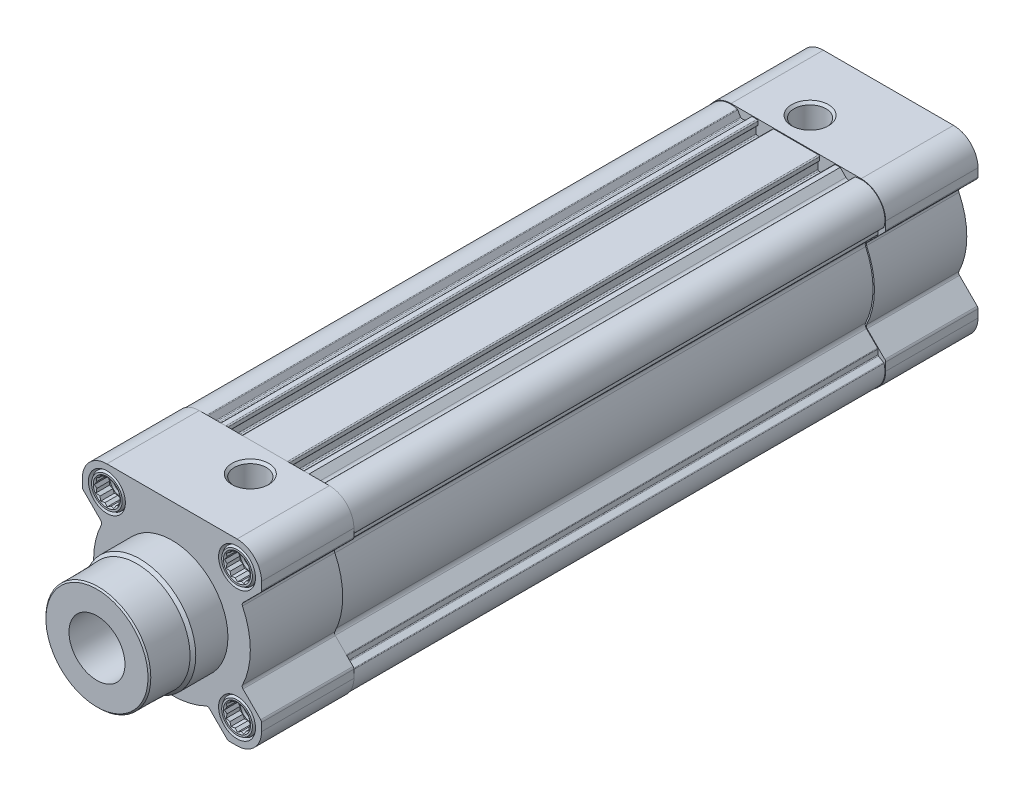
from build123d import *

# Parameters (mm, degrees)
BOSS_EXTRUDE1_DEPTH  = 33
BOSS_EXTRUDE2_DEPTH  = 190
SKETCH3_W            = 76.8
SKETCH3_H            = 76.8
CUT_EXTRUDE1_DEPTH   = 190
BOSS_EXTRUDE3_DEPTH  = 33
HOLE1_D              = 11.445
HOLE1_DEPTH          = 32
HOLE1_CSINK_D        = 13.157
HOLE1_CSINK_ANGLE    = 90
SKETCH8_W            = 24.5
SKETCH8_H            = 6.6
LPATTERN1_COUNT      = 2
LPATTERN1_PITCH      = 46.5
LPATTERN1_COUNT_DIR2 = 2
LPATTERN1_PITCH_DIR2 = 46.5
LPATTERN2_COUNT      = 2
LPATTERN2_PITCH      = 46.5
LPATTERN2_COUNT_DIR2 = 2
LPATTERN2_PITCH_DIR2 = 46.5
CUT_EXTRUDE2_DEPTH   = 5
LPATTERN3_COUNT      = 2
LPATTERN3_PITCH      = 46.5
LPATTERN3_COUNT_DIR2 = 2
LPATTERN3_PITCH_DIR2 = 46.5
LPATTERN4_COUNT      = 2
LPATTERN4_PITCH      = 46.5
LPATTERN4_COUNT_DIR2 = 2
LPATTERN4_PITCH_DIR2 = 46.5
HOLE2_D              = 11.445
HOLE2_DEPTH          = 32
HOLE2_CSINK_D        = 13.157
HOLE2_CSINK_ANGLE    = 90
HOLE3_D              = 13.2
HOLE3_DEPTH          = 24.5
LPATTERN5_COUNT      = 2
LPATTERN5_PITCH      = 46.5
LPATTERN5_COUNT_DIR2 = 2
LPATTERN5_PITCH_DIR2 = 46.5
LPATTERN6_COUNT      = 2
LPATTERN6_PITCH      = 46.5
LPATTERN6_COUNT_DIR2 = 2
LPATTERN6_PITCH_DIR2 = 46.5
LPATTERN7_COUNT      = 2
LPATTERN7_PITCH      = 46.5
LPATTERN7_COUNT_DIR2 = 2
LPATTERN7_PITCH_DIR2 = 46.5
CUT_EXTRUDE3_DEPTH   = 5
LPATTERN8_COUNT      = 2
LPATTERN8_PITCH      = 46.5
LPATTERN8_COUNT_DIR2 = 2
LPATTERN8_PITCH_DIR2 = 46.5


with BuildPart() as part:
    # Sketch1 → Boss-Extrude1 (new body)
    with BuildSketch(Plane.XY.offset(-33)):
        with BuildLine():
            Line((-31.707106781, 19.686291501), (-25.38500441, 13.36418913))
            ThreePointArc((-25.38500441, 13.36418913), (-25.10600235, 12.82318278), (-25.192383219, 12.220631233))
            ThreePointArc((-25.192383219, 12.220631233), (-28, 0), (-25.192383219, -12.220631233))
            ThreePointArc((-25.192383219, -12.220631233), (-25.10600235, -12.82318278), (-25.38500441, -13.36418913))
            Line((-25.38500441, -13.36418913), (-31.707106781, -19.686291501))
            ThreePointArc((-31.707106781, -19.686291501), (-31.923879533, -20.01071485), (-32, -20.393398282))
            Line((-32, -20.393398282), (-32, -23.25))
            ThreePointArc((-32, -23.25), (-29.437184335, -29.437184335), (-23.25, -32))
            Line((-23.25, -32), (-20.393398282, -32))
            ThreePointArc((-20.393398282, -32), (-20.01071485, -31.923879533), (-19.686291501, -31.707106781))
            Line((-19.686291501, -31.707106781), (-13.36418913, -25.38500441))
            ThreePointArc((-13.36418913, -25.38500441), (-12.82318278, -25.10600235), (-12.220631233, -25.192383219))
            ThreePointArc((-12.220631233, -25.192383219), (0, -28), (12.220631233, -25.192383219))
            ThreePointArc((12.220631233, -25.192383219), (12.82318278, -25.10600235), (13.36418913, -25.38500441))
            Line((13.36418913, -25.38500441), (19.686291501, -31.707106781))
            ThreePointArc((19.686291501, -31.707106781), (20.01071485, -31.923879533), (20.393398282, -32))
            Line((20.393398282, -32), (23.25, -32))
            ThreePointArc((23.25, -32), (29.437184335, -29.437184335), (32, -23.25))
            Line((32, -23.25), (32, -20.393398282))
            ThreePointArc((32, -20.393398282), (31.923879533, -20.01071485), (31.707106781, -19.686291501))
            Line((31.707106781, -19.686291501), (25.38500441, -13.36418913))
            ThreePointArc((25.38500441, -13.36418913), (25.10600235, -12.82318278), (25.192383219, -12.220631233))
            ThreePointArc((25.192383219, -12.220631233), (28, 0), (25.192383219, 12.220631233))
            ThreePointArc((25.192383219, 12.220631233), (25.10600235, 12.82318278), (25.38500441, 13.36418913))
            Line((25.38500441, 13.36418913), (31.707106781, 19.686291501))
            ThreePointArc((31.707106781, 19.686291501), (31.923879533, 20.01071485), (32, 20.393398282))
            Line((32, 20.393398282), (32, 23.25))
            ThreePointArc((32, 23.25), (29.437184335, 29.437184335), (23.25, 32))
            Line((23.25, 32), (-23.25, 32))
            ThreePointArc((-23.25, 32), (-29.437184335, 29.437184335), (-32, 23.25))
            Line((-32, 23.25), (-32, 20.393398282))
            ThreePointArc((-32, 20.393398282), (-31.923879533, 20.01071485), (-31.707106781, 19.686291501))
        make_face()
    extrude(amount=BOSS_EXTRUDE1_DEPTH)

    # Sketch2 → Boss-Extrude2 (add)
    with BuildSketch(Plane.XY.offset(-33)):
        with BuildLine():
            Line((-31.75, 20.08273811), (-25.296126931, 13.628865041))
            ThreePointArc((-25.296126931, 13.628865041), (-24.87846612, 12.822305384), (-25.00284256, 11.922577907))
            ThreePointArc((-25.00284256, 11.922577907), (-27.7, 0), (-25.00284256, -11.922577907))
            ThreePointArc((-25.00284256, -11.922577907), (-24.87846612, -12.822305384), (-25.296126931, -13.628865041))
            Line((-25.296126931, -13.628865041), (-31.75, -20.08273811))
            Line((-31.75, -20.08273811), (-31.75, -23.5))
            ThreePointArc((-31.75, -23.5), (-29.333630945, -29.333630945), (-23.5, -31.75))
            Line((-23.5, -31.75), (-20.08273811, -31.75))
            Line((-20.08273811, -31.75), (-13.628865041, -25.296126931))
            ThreePointArc((-13.628865041, -25.296126931), (-12.822305384, -24.87846612), (-11.922577907, -25.00284256))
            ThreePointArc((-11.922577907, -25.00284256), (0, -27.7), (11.922577907, -25.00284256))
            ThreePointArc((11.922577907, -25.00284256), (12.822305384, -24.87846612), (13.628865041, -25.296126931))
            Line((13.628865041, -25.296126931), (20.08273811, -31.75))
            Line((20.08273811, -31.75), (23.5, -31.75))
            ThreePointArc((23.5, -31.75), (29.333630945, -29.333630945), (31.75, -23.5))
            Line((31.75, -23.5), (31.75, -20.08273811))
            Line((31.75, -20.08273811), (25.296126931, -13.628865041))
            ThreePointArc((25.296126931, -13.628865041), (24.87846612, -12.822305384), (25.00284256, -11.922577907))
            ThreePointArc((25.00284256, -11.922577907), (27.7, 0), (25.00284256, 11.922577907))
            ThreePointArc((25.00284256, 11.922577907), (24.87846612, 12.822305384), (25.296126931, 13.628865041))
            Line((25.296126931, 13.628865041), (31.75, 20.08273811))
            Line((31.75, 20.08273811), (31.75, 23.5))
            ThreePointArc((31.75, 23.5), (29.333630945, 29.333630945), (23.5, 31.75))
            Line((23.5, 31.75), (-23.5, 31.75))
            ThreePointArc((-23.5, 31.75), (-29.333630945, 29.333630945), (-31.75, 23.5))
            Line((-31.75, 23.5), (-31.75, 20.08273811))
        make_face()
    extrude(amount=-BOSS_EXTRUDE2_DEPTH)

    # Sketch3 → Cut-Extrude1 (cut)
    with BuildSketch(Plane.XY.offset(-33)):
        Rectangle(SKETCH3_W, SKETCH3_H)
        with BuildLine():
            Line((-20.847700821, -31.237836974), (-19.815492663, -29.45))
            ThreePointArc((-19.815492663, -29.45), (-19.669082502, -29.303589838), (-19.469082502, -29.25))
            Line((-19.469082502, -29.25), (-17.748423535, -29.25))
            ThreePointArc((-17.748423535, -29.25), (-17.595350162, -29.219551813), (-17.465580823, -29.132842712))
            Line((-17.465580823, -29.132842712), (-13.478767922, -25.146029812))
            ThreePointArc((-13.478767922, -25.146029812), (-12.674014627, -24.728680623), (-11.775791832, -24.851171536))
            ThreePointArc((-11.775791832, -24.851171536), (0, -27.5), (11.775791832, -24.851171536))
            ThreePointArc((11.775791832, -24.851171536), (12.674014627, -24.728680623), (13.478767922, -25.146029812))
            Line((13.478767922, -25.146029812), (17.465580823, -29.132842712))
            ThreePointArc((17.465580823, -29.132842712), (17.595350162, -29.219551813), (17.748423535, -29.25))
            Line((17.748423535, -29.25), (19.469082502, -29.25))
            ThreePointArc((19.469082502, -29.25), (19.669082502, -29.303589838), (19.815492663, -29.45))
            Line((19.815492663, -29.45), (20.847700821, -31.237836974))
            ThreePointArc((20.847700821, -31.237836974), (20.947545902, -31.352806276), (21.083122856, -31.422130658))
            ThreePointArc((21.083122856, -31.422130658), (29.304341623, -29.304341623), (31.422130658, -21.083122856))
            ThreePointArc((31.422130658, -21.083122856), (31.352806276, -20.947545902), (31.237836974, -20.847700821))
            Line((31.237836974, -20.847700821), (29.45, -19.815492663))
            ThreePointArc((29.45, -19.815492663), (29.303589838, -19.669082502), (29.25, -19.469082502))
            Line((29.25, -19.469082502), (29.25, -17.748423535))
            ThreePointArc((29.25, -17.748423535), (29.219551813, -17.595350162), (29.132842712, -17.465580823))
            Line((29.132842712, -17.465580823), (25.146029812, -13.478767922))
            ThreePointArc((25.146029812, -13.478767922), (24.728680623, -12.674014627), (24.851171536, -11.775791832))
            ThreePointArc((24.851171536, -11.775791832), (27.5, 0), (24.851171536, 11.775791832))
            ThreePointArc((24.851171536, 11.775791832), (24.728680623, 12.674014627), (25.146029812, 13.478767922))
            Line((25.146029812, 13.478767922), (29.132842712, 17.465580823))
            ThreePointArc((29.132842712, 17.465580823), (29.219551813, 17.595350162), (29.25, 17.748423535))
            Line((29.25, 17.748423535), (29.25, 19.469082502))
            ThreePointArc((29.25, 19.469082502), (29.303589838, 19.669082502), (29.45, 19.815492663))
            Line((29.45, 19.815492663), (31.237836974, 20.847700821))
            ThreePointArc((31.237836974, 20.847700821), (31.352806276, 20.947545902), (31.422130658, 21.083122856))
            ThreePointArc((31.422130658, 21.083122856), (29.304341623, 29.304341623), (21.083122856, 31.422130658))
            ThreePointArc((21.083122856, 31.422130658), (20.947545902, 31.352806276), (20.847700821, 31.237836974))
            Line((20.847700821, 31.237836974), (19.815492663, 29.45))
            ThreePointArc((19.815492663, 29.45), (19.669082502, 29.303589838), (19.469082502, 29.25))
            Line((19.469082502, 29.25), (18.871320344, 29.25))
            ThreePointArc((18.871320344, 29.25), (18.297295195, 29.364180701), (17.810660172, 29.689339828))
            Line((17.810660172, 29.689339828), (15.75, 31.75))
            Line((15.75, 31.75), (14, 31.75))
            ThreePointArc((14, 31.75), (13.717157288, 31.632842712), (13.6, 31.35))
            Line((13.6, 31.35), (13.6, 30.15))
            ThreePointArc((13.6, 30.15), (13.658578644, 30.008578644), (13.8, 29.95))
            Line((13.8, 29.95), (14.05, 29.95))
            ThreePointArc((14.05, 29.95), (14.191421356, 29.891421356), (14.25, 29.75))
            Line((14.25, 29.75), (14.25, 27.15))
            ThreePointArc((14.25, 27.15), (14.132842712, 26.867157288), (13.85, 26.75))
            Line((13.85, 26.75), (8.15, 26.75))
            ThreePointArc((8.15, 26.75), (7.867157288, 26.867157288), (7.75, 27.15))
            Line((7.75, 27.15), (7.75, 29.75))
            ThreePointArc((7.75, 29.75), (7.808578644, 29.891421356), (7.95, 29.95))
            Line((7.95, 29.95), (8.2, 29.95))
            ThreePointArc((8.2, 29.95), (8.341421356, 30.008578644), (8.4, 30.15))
            Line((8.4, 30.15), (8.4, 31.35))
            ThreePointArc((8.4, 31.35), (8.282842712, 31.632842712), (8, 31.75))
            Line((8, 31.75), (-8, 31.75))
            ThreePointArc((-8, 31.75), (-8.282842712, 31.632842712), (-8.4, 31.35))
            Line((-8.4, 31.35), (-8.4, 30.15))
            ThreePointArc((-8.4, 30.15), (-8.341421356, 30.008578644), (-8.2, 29.95))
            Line((-8.2, 29.95), (-7.95, 29.95))
            ThreePointArc((-7.95, 29.95), (-7.808578644, 29.891421356), (-7.75, 29.75))
            Line((-7.75, 29.75), (-7.75, 27.15))
            ThreePointArc((-7.75, 27.15), (-7.867157288, 26.867157288), (-8.15, 26.75))
            Line((-8.15, 26.75), (-13.85, 26.75))
            ThreePointArc((-13.85, 26.75), (-14.132842712, 26.867157288), (-14.25, 27.15))
            Line((-14.25, 27.15), (-14.25, 29.75))
            ThreePointArc((-14.25, 29.75), (-14.191421356, 29.891421356), (-14.05, 29.95))
            Line((-14.05, 29.95), (-13.8, 29.95))
            ThreePointArc((-13.8, 29.95), (-13.658578644, 30.008578644), (-13.6, 30.15))
            Line((-13.6, 30.15), (-13.6, 31.35))
            ThreePointArc((-13.6, 31.35), (-13.717157288, 31.632842712), (-14, 31.75))
            Line((-14, 31.75), (-15.75, 31.75))
            Line((-15.75, 31.75), (-17.810660172, 29.689339828))
            ThreePointArc((-17.810660172, 29.689339828), (-18.297295195, 29.364180701), (-18.871320344, 29.25))
            Line((-18.871320344, 29.25), (-19.469082502, 29.25))
            ThreePointArc((-19.469082502, 29.25), (-19.669082502, 29.303589838), (-19.815492663, 29.45))
            Line((-19.815492663, 29.45), (-20.847700821, 31.237836974))
            ThreePointArc((-20.847700821, 31.237836974), (-20.947545902, 31.352806276), (-21.083122856, 31.422130658))
            ThreePointArc((-21.083122856, 31.422130658), (-29.304341623, 29.304341623), (-31.422130658, 21.083122856))
            ThreePointArc((-31.422130658, 21.083122856), (-31.352806276, 20.947545902), (-31.237836974, 20.847700821))
            Line((-31.237836974, 20.847700821), (-29.45, 19.815492663))
            ThreePointArc((-29.45, 19.815492663), (-29.303589838, 19.669082502), (-29.25, 19.469082502))
            Line((-29.25, 19.469082502), (-29.25, 17.748423535))
            ThreePointArc((-29.25, 17.748423535), (-29.219551813, 17.595350162), (-29.132842712, 17.465580823))
            Line((-29.132842712, 17.465580823), (-25.146029812, 13.478767922))
            ThreePointArc((-25.146029812, 13.478767922), (-24.728680623, 12.674014627), (-24.851171536, 11.775791832))
            ThreePointArc((-24.851171536, 11.775791832), (-27.5, 0), (-24.851171536, -11.775791832))
            ThreePointArc((-24.851171536, -11.775791832), (-24.728680623, -12.674014627), (-25.146029812, -13.478767922))
            Line((-25.146029812, -13.478767922), (-29.132842712, -17.465580823))
            ThreePointArc((-29.132842712, -17.465580823), (-29.219551813, -17.595350162), (-29.25, -17.748423535))
            Line((-29.25, -17.748423535), (-29.25, -19.469082502))
            ThreePointArc((-29.25, -19.469082502), (-29.303589838, -19.669082502), (-29.45, -19.815492663))
            Line((-29.45, -19.815492663), (-31.237836974, -20.847700821))
            ThreePointArc((-31.237836974, -20.847700821), (-31.352806276, -20.947545902), (-31.422130658, -21.083122856))
            ThreePointArc((-31.422130658, -21.083122856), (-29.304341623, -29.304341623), (-21.083122856, -31.422130658))
            ThreePointArc((-21.083122856, -31.422130658), (-20.947545902, -31.352806276), (-20.847700821, -31.237836974))
        make_face(mode=Mode.SUBTRACT)
    extrude(amount=-CUT_EXTRUDE1_DEPTH, mode=Mode.SUBTRACT)

    # Sketch4 → Boss-Extrude3 (add)
    with BuildSketch(Plane.XY.offset(-256)):
        with BuildLine():
            Line((-31.707106781, 19.686291501), (-25.38500441, 13.36418913))
            ThreePointArc((-25.38500441, 13.36418913), (-25.10600235, 12.82318278), (-25.192383219, 12.220631233))
            ThreePointArc((-25.192383219, 12.220631233), (-28, 0), (-25.192383219, -12.220631233))
            ThreePointArc((-25.192383219, -12.220631233), (-25.10600235, -12.82318278), (-25.38500441, -13.36418913))
            Line((-25.38500441, -13.36418913), (-31.707106781, -19.686291501))
            ThreePointArc((-31.707106781, -19.686291501), (-31.923879533, -20.01071485), (-32, -20.393398282))
            Line((-32, -20.393398282), (-32, -23.25))
            ThreePointArc((-32, -23.25), (-29.437184335, -29.437184335), (-23.25, -32))
            Line((-23.25, -32), (-20.393398282, -32))
            ThreePointArc((-20.393398282, -32), (-20.01071485, -31.923879533), (-19.686291501, -31.707106781))
            Line((-19.686291501, -31.707106781), (-13.36418913, -25.38500441))
            ThreePointArc((-13.36418913, -25.38500441), (-12.82318278, -25.10600235), (-12.220631233, -25.192383219))
            ThreePointArc((-12.220631233, -25.192383219), (0, -28), (12.220631233, -25.192383219))
            ThreePointArc((12.220631233, -25.192383219), (12.82318278, -25.10600235), (13.36418913, -25.38500441))
            Line((13.36418913, -25.38500441), (19.686291501, -31.707106781))
            ThreePointArc((19.686291501, -31.707106781), (20.01071485, -31.923879533), (20.393398282, -32))
            Line((20.393398282, -32), (23.25, -32))
            ThreePointArc((23.25, -32), (29.437184335, -29.437184335), (32, -23.25))
            Line((32, -23.25), (32, -20.393398282))
            ThreePointArc((32, -20.393398282), (31.923879533, -20.01071485), (31.707106781, -19.686291501))
            Line((31.707106781, -19.686291501), (25.38500441, -13.36418913))
            ThreePointArc((25.38500441, -13.36418913), (25.10600235, -12.82318278), (25.192383219, -12.220631233))
            ThreePointArc((25.192383219, -12.220631233), (28, 0), (25.192383219, 12.220631233))
            ThreePointArc((25.192383219, 12.220631233), (25.10600235, 12.82318278), (25.38500441, 13.36418913))
            Line((25.38500441, 13.36418913), (31.707106781, 19.686291501))
            ThreePointArc((31.707106781, 19.686291501), (31.923879533, 20.01071485), (32, 20.393398282))
            Line((32, 20.393398282), (32, 23.25))
            ThreePointArc((32, 23.25), (29.437184335, 29.437184335), (23.25, 32))
            Line((23.25, 32), (-23.25, 32))
            ThreePointArc((-23.25, 32), (-29.437184335, 29.437184335), (-32, 23.25))
            Line((-32, 23.25), (-32, 20.393398282))
            ThreePointArc((-32, 20.393398282), (-31.923879533, 20.01071485), (-31.707106781, 19.686291501))
        make_face()
    extrude(amount=BOSS_EXTRUDE3_DEPTH)

    # Sketch5 → Revolve1 (revolve)
    with BuildSketch(Plane(origin=(0, 0, 0), x_dir=(0, 0, -1), z_dir=(1, 0, 0))):
        Polygon((-26.8, 0), (-26.8, 18.241665039), (-26.3, 18.741665039), (-12.517765157, 18.982234843), (-11.5, 20), (0, 20), (0, 0), align=None)
    revolve(axis=Axis((0, 0, 0), (0, 0, 1)))

    # Hole1
    with Locations(Plane(origin=(0, 32, 0), x_dir=(1, 0, 0), z_dir=(0, 1, 0))):
        with Locations((5.5, 22.5)):
            CounterSinkHole(HOLE1_D / 2, HOLE1_CSINK_D / 2, depth=HOLE1_DEPTH, counter_sink_angle=HOLE1_CSINK_ANGLE)

    # Sketch8 → Cut-Revolve1 (revolve, cut)
    with BuildSketch(Plane(origin=(23.25, 0, 0), x_dir=(0, 0, -1), z_dir=(1, 0, 0))):
        with Locations((12.25, 26.55)):
            Rectangle(SKETCH8_W, SKETCH8_H)
    cut_revolve1 = revolve(axis=Axis((23.25, 23.25, -24.5), (0, 0, 1)), mode=Mode.SUBTRACT)

    # LPattern1: Cut-Revolve1 2 × 2
    with Locations(*[(-i * LPATTERN1_PITCH, -j * LPATTERN1_PITCH_DIR2, 0) for i in range(LPATTERN1_COUNT) for j in range(LPATTERN1_COUNT_DIR2) if (i, j) != (0, 0)]):
        add(cut_revolve1, mode=Mode.SUBTRACT)

    # Sketch10 → Revolve2 (revolve)
    with BuildSketch(Plane(origin=(23.25, 0, 0), x_dir=(0, 0, -1), z_dir=(1, 0, 0))):
        Polygon((0, 23.25), (0, 28.730384758), (0.9, 29.25), (24.5, 29.25), (24.5, 23.25), align=None)
    revolve2 = revolve(axis=Axis((23.25, 23.25, -24.5), (0, 0, 1)))

    # LPattern2: Revolve2 2 × 2
    with Locations(*[(-i * LPATTERN2_PITCH, -j * LPATTERN2_PITCH_DIR2, 0) for i in range(LPATTERN2_COUNT) for j in range(LPATTERN2_COUNT_DIR2) if (i, j) != (0, 0)]):
        add(revolve2)

    # Sketch12 → Cut-Revolve2 (revolve, cut)
    with BuildSketch(Plane(origin=(23.25, 0, 0), x_dir=(0, 0, -1), z_dir=(1, 0, 0))):
        Polygon((0, 23.25), (0, 28.1), (0.490747729, 27.25), (6, 27.25), (6.6765, 26.5735), (20.2, 26.5735), (22.11882362, 23.25), align=None)
    cut_revolve2 = revolve(axis=Axis((23.25, 23.25, -22.11882362), (0, 0, 1)), mode=Mode.SUBTRACT)

    # Sketch13 → Cut-Extrude2 (cut, symmetric)
    with BuildSketch(Plane.XY):
        Polygon((18.631197846, 23.25), (19.25, 22.17820323), (19.25, 20.940598923), (20.32179677, 20.32179677), (20.940598923, 19.25), (22.17820323, 19.25), (23.25, 18.631197846), (24.32179677, 19.25), (25.559401077, 19.25), (26.17820323, 20.32179677), (27.25, 20.940598923), (27.25, 22.17820323), (27.868802154, 23.25), (27.25, 24.32179677), (27.25, 25.559401077), (26.17820323, 26.17820323), (25.559401077, 27.25), (24.32179677, 27.25), (23.25, 27.868802154), (22.17820323, 27.25), (20.940598923, 27.25), (20.32179677, 26.17820323), (19.25, 25.559401077), (19.25, 24.32179677), align=None)
    cut_extrude2 = extrude(amount=CUT_EXTRUDE2_DEPTH, both=True, mode=Mode.SUBTRACT)

    # LPattern3: Cut-Revolve2 2 × 2
    with Locations(*[(-i * LPATTERN3_PITCH, -j * LPATTERN3_PITCH_DIR2, 0) for i in range(LPATTERN3_COUNT) for j in range(LPATTERN3_COUNT_DIR2) if (i, j) != (0, 0)]):
        add(cut_revolve2, mode=Mode.SUBTRACT)

    # LPattern4: Cut-Extrude2 2 × 2
    with Locations(*[(-i * LPATTERN4_PITCH, -j * LPATTERN4_PITCH_DIR2, 0) for i in range(LPATTERN4_COUNT) for j in range(LPATTERN4_COUNT_DIR2) if (i, j) != (0, 0)]):
        add(cut_extrude2, mode=Mode.SUBTRACT)

    # Sketch16 → Revolve3 (revolve)
    with BuildSketch(Plane(origin=(0, 0, 0), x_dir=(0, 0, -1), z_dir=(1, 0, 0))):
        Polygon((256, 0), (256, 20), (259.5, 20), (260, 19.5), (260, 0), align=None)
    revolve(axis=Axis((0, 0, -260), (0, 0, 1)))

    # Hole2
    with Locations(Plane(origin=(0, 32, 0), x_dir=(1, 0, 0), z_dir=(0, 1, 0))):
        with Locations((-5.5, 233.5)):
            CounterSinkHole(HOLE2_D / 2, HOLE2_CSINK_D / 2, depth=HOLE2_DEPTH, counter_sink_angle=HOLE2_CSINK_ANGLE)

    # Hole3
    with Locations(Plane(origin=(0, 0, -256), x_dir=(-1, 0, 0), z_dir=(0, 0, -1))):
        with Locations((-23.25, 23.25)):
            hole3 = Hole(HOLE3_D / 2, depth=HOLE3_DEPTH)

    # LPattern5: Hole3 2 × 2
    with Locations(*[(-i * LPATTERN5_PITCH, -j * LPATTERN5_PITCH_DIR2, 0) for i in range(LPATTERN5_COUNT) for j in range(LPATTERN5_COUNT_DIR2) if (i, j) != (0, 0)]):
        add(hole3, mode=Mode.SUBTRACT)

    # Sketch22 → Revolve4 (revolve)
    with BuildSketch(Plane(origin=(23.25, 0, 0), x_dir=(0, 0, -1), z_dir=(1, 0, 0))):
        Polygon((231.5, 23.25), (231.5, 29.25), (255.1, 29.25), (256, 28.730384758), (256, 23.25), align=None)
    revolve4 = revolve(axis=Axis((23.25, 23.25, -256), (0, 0, 1)))

    # LPattern6: Revolve4 2 × 2
    with Locations(*[(-i * LPATTERN6_PITCH, -j * LPATTERN6_PITCH_DIR2, 0) for i in range(LPATTERN6_COUNT) for j in range(LPATTERN6_COUNT_DIR2) if (i, j) != (0, 0)]):
        add(revolve4)

    # Sketch24 → Cut-Revolve3 (revolve, cut)
    with BuildSketch(Plane(origin=(23.25, 0, 0), x_dir=(0, 0, -1), z_dir=(1, 0, 0))):
        Polygon((233.88117638, 23.25), (235.8, 26.5735), (249.3235, 26.5735), (250, 27.25), (255.509252271, 27.25), (256, 28.1), (256, 23.25), align=None)
    cut_revolve3 = revolve(axis=Axis((23.25, 23.25, -256), (0, 0, 1)), mode=Mode.SUBTRACT)

    # LPattern7: Cut-Revolve3 2 × 2
    with Locations(*[(-i * LPATTERN7_PITCH, -j * LPATTERN7_PITCH_DIR2, 0) for i in range(LPATTERN7_COUNT) for j in range(LPATTERN7_COUNT_DIR2) if (i, j) != (0, 0)]):
        add(cut_revolve3, mode=Mode.SUBTRACT)

    # Sketch26 → Cut-Extrude3 (cut, symmetric)
    with BuildSketch(Plane.XY.offset(-256)):
        Polygon((18.631197846, 23.25), (19.25, 22.17820323), (19.25, 20.940598923), (20.32179677, 20.32179677), (20.940598923, 19.25), (22.17820323, 19.25), (23.25, 18.631197846), (24.32179677, 19.25), (25.559401077, 19.25), (26.17820323, 20.32179677), (27.25, 20.940598923), (27.25, 22.17820323), (27.868802154, 23.25), (27.25, 24.32179677), (27.25, 25.559401077), (26.17820323, 26.17820323), (25.559401077, 27.25), (24.32179677, 27.25), (23.25, 27.868802154), (22.17820323, 27.25), (20.940598923, 27.25), (20.32179677, 26.17820323), (19.25, 25.559401077), (19.25, 24.32179677), align=None)
    cut_extrude3 = extrude(amount=CUT_EXTRUDE3_DEPTH, both=True, mode=Mode.SUBTRACT)

    # LPattern8: Cut-Extrude3 2 × 2
    with Locations(*[(-i * LPATTERN8_PITCH, -j * LPATTERN8_PITCH_DIR2, 0) for i in range(LPATTERN8_COUNT) for j in range(LPATTERN8_COUNT_DIR2) if (i, j) != (0, 0)]):
        add(cut_extrude3, mode=Mode.SUBTRACT)

    # Sketch28 → Cut-Revolve4 (revolve, cut)
    with BuildSketch(Plane(origin=(0, 0, 0), x_dir=(0, 0, -1), z_dir=(1, 0, 0))):
        Polygon((-26.8, 0), (-26.8, 10), (56.333333333, 10), (56.333333333, 25), (223, 25), (223, 0), align=None)
    revolve(axis=Axis((0, 0, -223), (0, 0, 1)), mode=Mode.SUBTRACT)


solid = part.part
